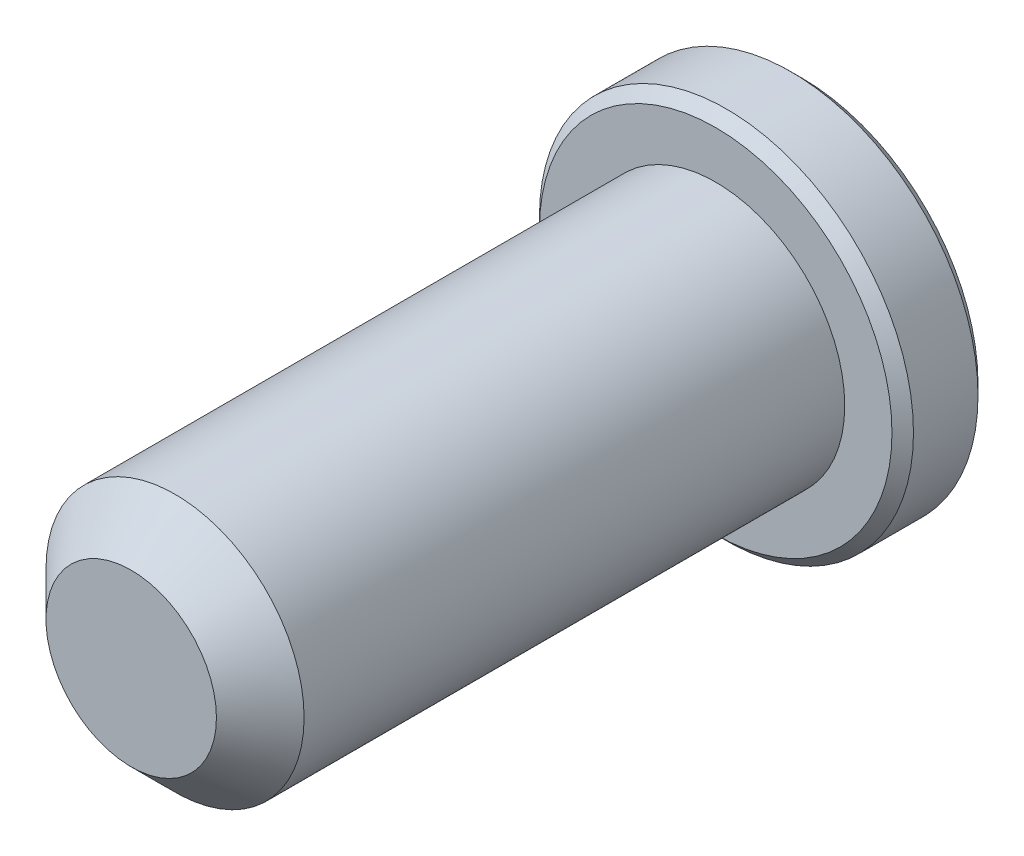
from build123d import *

# Parameters (mm, degrees)
EXTRUDE1_START     = -3.38455
SKETCH1_R          = 1.7526
EXTRUDE1_DEPTH     = 7.9375
EXTRUDE2_START     = -4.55295
SKETCH6_R          = 2.54
EXTRUDE2_DEPTH     = 1.1684
CUT_EXTRUDE1_DEPTH = 0.8763
SKETCH8_R          = 0.916543552
CUT_EXTRUDE2_DEPTH = 0.8763
CUT_EXTRUDE2_TAPER = 45
CHAMFER1_SIZE      = 0.14605
CHAMFER2_SIZE      = 0.5953125


with BuildPart() as part:
    # Sketch1 → Extrude1 (new body)
    with BuildSketch(Plane.XY.offset(EXTRUDE1_START)):
        Circle(SKETCH1_R)
    extrude(amount=EXTRUDE1_DEPTH)

    # Sketch6 → Extrude2 (add)
    with BuildSketch(Plane.XY.offset(EXTRUDE2_START)):
        Circle(SKETCH6_R)
    extrude(amount=EXTRUDE2_DEPTH)

    # Sketch7 → Cut-Extrude1 (cut)
    with BuildSketch(Plane.XY.offset(-4.55295)):
        Polygon((0, 0.916543552), (-0.79375, 0.458271776), (-0.79375, -0.458271776), (0, -0.916543552), (0.79375, -0.458271776), (0.79375, 0.458271776), align=None)
    extrude(amount=CUT_EXTRUDE1_DEPTH, mode=Mode.SUBTRACT)

    # Sketch8 → Cut-Extrude2 (cut)
    with BuildSketch(Plane.XY.offset(-4.55295)):
        Circle(SKETCH8_R)
    extrude(amount=CUT_EXTRUDE2_DEPTH, taper=CUT_EXTRUDE2_TAPER, mode=Mode.SUBTRACT)

    # Chamfer1
    chamfer1_edges = [part.edges().sort_by_distance(p)[0] for p in [
        (-2.54, 0, -3.38455),
        (-2.54, 0, -4.55295),
    ]]
    chamfer(chamfer1_edges, length=CHAMFER1_SIZE)

    # Chamfer2
    chamfer2_edges = [part.edges().sort_by_distance(p)[0] for p in [
        (-1.7526, 0, 4.55295),
    ]]
    chamfer(chamfer2_edges, length=CHAMFER2_SIZE)


solid = part.part
